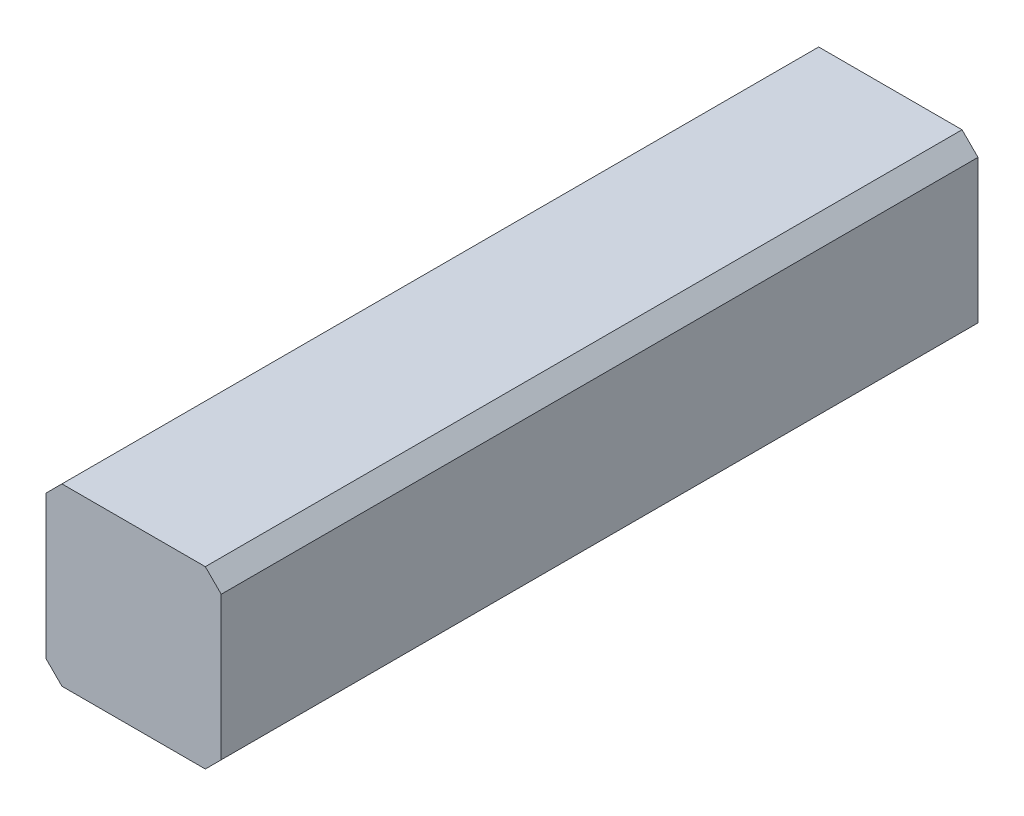
from build123d import *

# Parameters (mm, degrees)
BOSS_EXTRU_1_DEPTH = 95


with BuildPart() as part:
    # Esquisse1 → Boss.-Extru.1 (new body)
    with BuildSketch(Plane.XY):
        Polygon((-11, 9), (-9, 11), (9, 11), (11, 9), (11, -9), (9, -11), (-9, -11), (-11, -9), align=None)
    extrude(amount=BOSS_EXTRU_1_DEPTH)


solid = part.part
